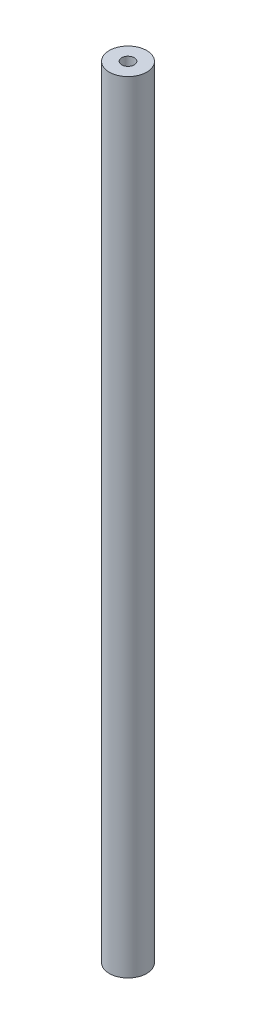
from build123d import *

# Parameters (mm, degrees)
SKETCH_1_R      = 3
SKETCH_1_R_2    = 1
EXTRUDE_1_DEPTH = 125


with BuildPart() as part:
    # 草图1 → 凸台-拉伸1 (new body)
    with BuildSketch(Plane(origin=(0, 0, 0), x_dir=(1, 0, 0), z_dir=(0, 1, 0))):
        Circle(SKETCH_1_R)
        Circle(SKETCH_1_R_2, mode=Mode.SUBTRACT)
    extrude(amount=EXTRUDE_1_DEPTH)


solid = part.part
